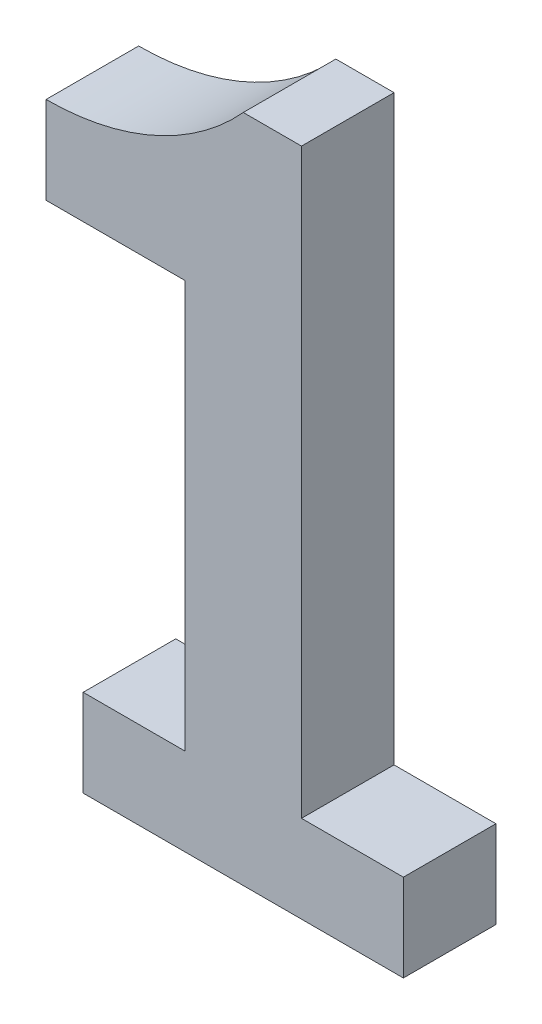
from build123d import *

# Parameters (mm, degrees)
SKETCH1_W           = 152.4
SKETCH1_H           = 114.3
BOSS_EXTRUDE1_DEPTH = 3.18
SKETCH2_OUTSIDE_W   = 192.506
SKETCH2_OUTSIDE_H   = 154.406
CUT_EXTRUDE2_DEPTH  = 3.18


with BuildPart() as part:
    # Sketch1 → Boss-Extrude1 (new body)
    with BuildSketch(Plane.XY):
        Rectangle(SKETCH1_W, SKETCH1_H)
    extrude(amount=BOSS_EXTRUDE1_DEPTH)

    # Sketch2 outside → Cut-Extrude2 (cut)
    with BuildSketch(Plane.XY.offset(3.18)):
        Rectangle(SKETCH2_OUTSIDE_W, SKETCH2_OUTSIDE_H)
        with BuildLine():
            Line((48.053666352, -28.069013415), (48.053666352, -48.069013415))
            Line((48.053666352, -48.069013415), (51.553666352, -48.069013415))
            Line((51.553666352, -48.069013415), (51.553666352, -51.069013415))
            Line((51.553666352, -51.069013415), (40.553666352, -51.069013415))
            Line((40.553666352, -51.069013415), (40.553666352, -48.069013415))
            Line((40.553666352, -48.069013415), (44.053666352, -48.069013415))
            Line((44.053666352, -48.069013415), (44.053666352, -34.069013415))
            Line((44.053666352, -34.069013415), (39.278768341, -34.069013415))
            Line((39.278768341, -34.069013415), (39.278768341, -31.069013415))
            ThreePointArc((39.278768341, -31.069013415), (42.983469512, -30.28546377), (46.053666352, -28.069013415))
            Line((46.053666352, -28.069013415), (48.053666352, -28.069013415))
        make_face(mode=Mode.SUBTRACT)
    extrude(amount=-CUT_EXTRUDE2_DEPTH, mode=Mode.SUBTRACT)


solid = part.part
